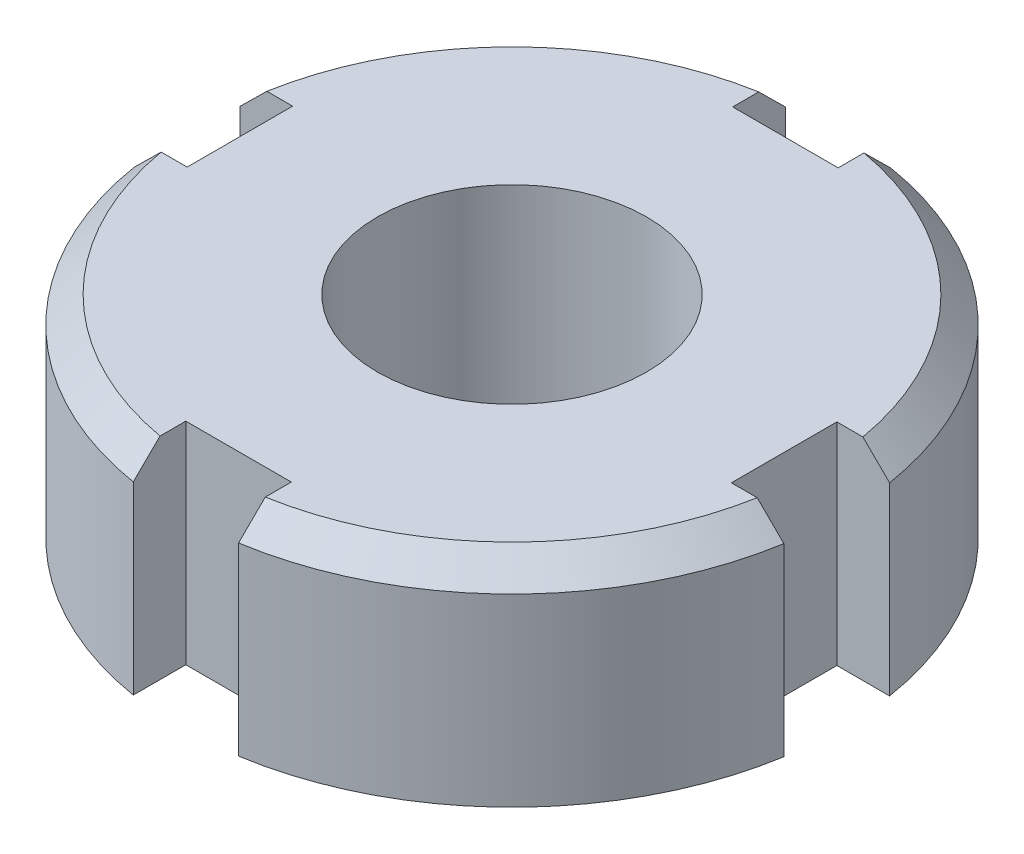
from build123d import *

# Parameters (mm, degrees)
SKETCH1_R               = 12.5
BOSS_EXTRUDE1_DEPTH     = 4
CUT_EXTRUDE1_DEPTH      = 5
CUT_EXTRUDE1_DEPTH_BACK = 5
CHAMFER1_SIZE           = 1
M12_TAPPED_HOLE1_D      = 10.2
M12_TAPPED_HOLE1_DEPTH  = 8


with BuildPart() as part:
    # Sketch1 → Boss-Extrude1 (new body, symmetric)
    with BuildSketch(Plane(origin=(0, 0, 0), x_dir=(1, 0, 0), z_dir=(0, 1, 0))):
        Circle(SKETCH1_R)
    extrude(amount=BOSS_EXTRUDE1_DEPTH, both=True)

    # Sketch2 → Cut-Extrude1 (cut, two sides)
    with BuildSketch(Plane(origin=(0, 0, 0), x_dir=(1, 0, 0), z_dir=(0, 1, 0))) as cut_extrude1_sk:
        with BuildLine():
            ThreePointArc((12.334864981, -2.025118736), (12.499974099, -0.025446565), (12.343007899, 1.974881264))
            Line((12.343007899, 1.974881264), (10.343007899, 1.974881264))
            Line((10.343007899, 1.974881264), (10.343007899, -2.025118736))
            Line((10.343007899, -2.025118736), (12.334864981, -2.025118736))
        make_face()
        with BuildLine():
            ThreePointArc((-2.025118736, -12.334864981), (-0.025446565, -12.499974099), (1.974881264, -12.343007899))
            Line((1.974881264, -12.343007899), (1.974881264, -10.343007899))
            Line((1.974881264, -10.343007899), (-2.025118736, -10.343007899))
            Line((-2.025118736, -10.343007899), (-2.025118736, -12.334864981))
        make_face()
        with BuildLine():
            Line((2.025118736, 10.343007899), (2.025118736, 12.334864981))
            ThreePointArc((2.025118736, 12.334864981), (0.025446565, 12.499974099), (-1.974881264, 12.343007899))
            Line((-1.974881264, 12.343007899), (-1.974881264, 10.343007899))
            Line((-1.974881264, 10.343007899), (2.025118736, 10.343007899))
        make_face()
        with BuildLine():
            ThreePointArc((-12.334864981, 2.025118736), (-12.499974099, 0.025446565), (-12.343007899, -1.974881264))
            Line((-12.343007899, -1.974881264), (-10.343007899, -1.974881264))
            Line((-10.343007899, -1.974881264), (-10.343007899, 2.025118736))
            Line((-10.343007899, 2.025118736), (-12.334864981, 2.025118736))
        make_face()
    extrude(amount=CUT_EXTRUDE1_DEPTH, mode=Mode.SUBTRACT)
    extrude(cut_extrude1_sk.sketch, amount=-CUT_EXTRUDE1_DEPTH_BACK, mode=Mode.SUBTRACT)

    # Chamfer1
    chamfer1_edges = [part.edges().sort_by_distance(p)[0] for p in [
        (8.856809889, 4, -8.820823011),
        (-8.820823011, 4, -8.856809889),
        (-8.856809889, 4, 8.820823011),
        (8.820823011, 4, 8.856809889),
    ]]
    chamfer(chamfer1_edges, length=CHAMFER1_SIZE)

    # M12 Tapped Hole1
    with Locations(Plane(origin=(0, 4, 0), x_dir=(1, 0, 0), z_dir=(0, 1, 0))):
        with Locations((0, 0)):
            Hole(M12_TAPPED_HOLE1_D / 2, depth=M12_TAPPED_HOLE1_DEPTH)


solid = part.part
